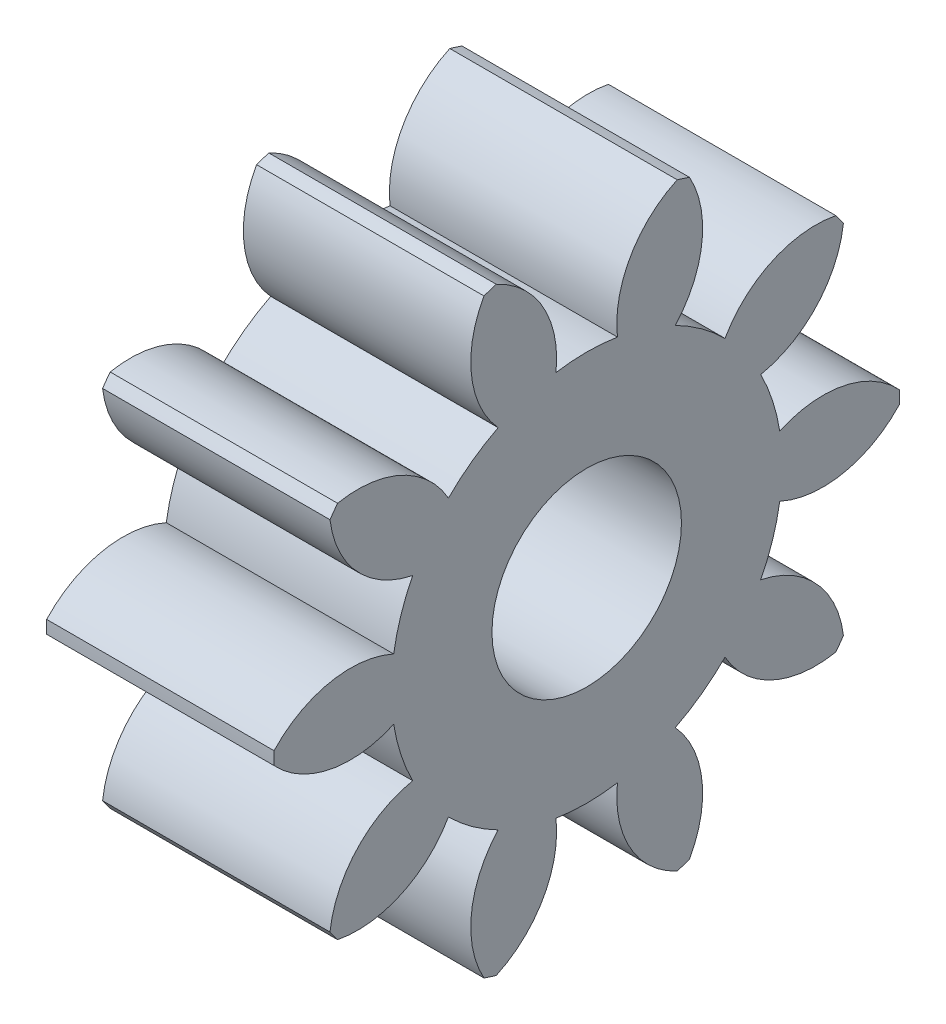
from build123d import *

# Parameters (mm, degrees)
BASPROSKE_W     = 6
BASPROSKE_H     = 8.25
TOOTHCUT_DEPTH  = 14.119641763
TEETHCUTS_COUNT = 10
TEETHCUTS_ANGLE = 324
BORSKE_R        = 2.5
BORE_DEPTH      = 50.0000508


with BuildPart() as part:
    # BasProSke → Base-Revolve (revolve)
    with BuildSketch(Plane(origin=(0, 0, 0), x_dir=(1, 0, 0), z_dir=(0, 1, 0)), mode=Mode.PRIVATE) as base_revolve_sk:
        with Locations((3, 4.125)):
            Rectangle(BASPROSKE_W, BASPROSKE_H)
    revolve(base_revolve_sk.sketch.rotate(Axis((-10, 0, 0), (1, 0, 0)), 180), axis=Axis((-10, 0, 0), (1, 0, 0)))

    # TooCutSke → ToothCut (cut, through all)
    with BuildSketch(Plane(origin=(0, 0, 0), x_dir=(0, 0, -1), z_dir=(1, 0, 0))):
        with BuildLine():
            ThreePointArc((0.810777273, 5.091094458), (0, 5.15525), (-0.810777273, 5.091094458))
            ThreePointArc((-0.810777273, 5.091094458), (-1.154893166, 6.765492881), (-2.421785774, 7.913102983))
            ThreePointArc((-2.421785774, 7.913102983), (0, 8.2754), (2.421785774, 7.913102983))
            ThreePointArc((2.421785774, 7.913102983), (1.154893166, 6.765492881), (0.810777273, 5.091094458))
        make_face()
    toothcut = extrude(amount=TOOTHCUT_DEPTH, mode=Mode.SUBTRACT)

    # TeethCuts: ToothCut ×10 about axis
    teethcuts_axis = Axis((-10, 0, 0), (1, 0, 0))
    for i in range(1, TEETHCUTS_COUNT):
        add(toothcut.rotate(teethcuts_axis, i * TEETHCUTS_ANGLE / (TEETHCUTS_COUNT - 1)), mode=Mode.SUBTRACT)

    # BorSke → Bore (cut, symmetric)
    with BuildSketch(Plane(origin=(0, 0, 0), x_dir=(0, 0, -1), z_dir=(1, 0, 0))):
        with Locations(Location((0, 0, 0), (0, 0, 180))):
            Circle(BORSKE_R)
    extrude(amount=BORE_DEPTH, both=True, mode=Mode.SUBTRACT)


solid = part.part
